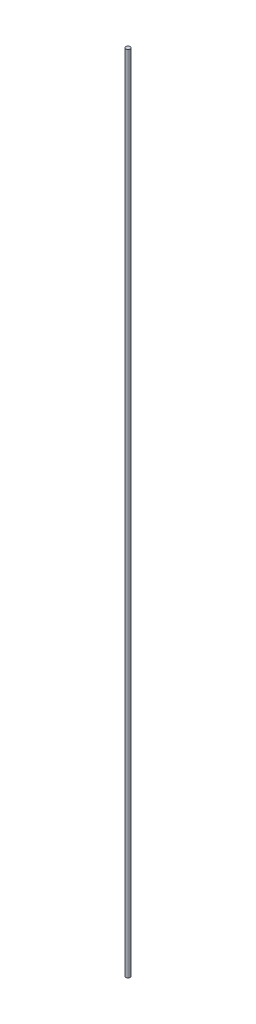
from build123d import *

# Parameters (mm, degrees)
ESBO_O1_R                = 3
RESSALTO_EXTRUS_O1_DEPTH = 1124


with BuildPart() as part:
    # Esboço1 → Ressalto-extrusão1 (new body)
    with BuildSketch(Plane(origin=(0, 0, 0), x_dir=(1, 0, 0), z_dir=(0, 1, 0))):
        Circle(ESBO_O1_R)
    extrude(amount=RESSALTO_EXTRUS_O1_DEPTH)


solid = part.part
